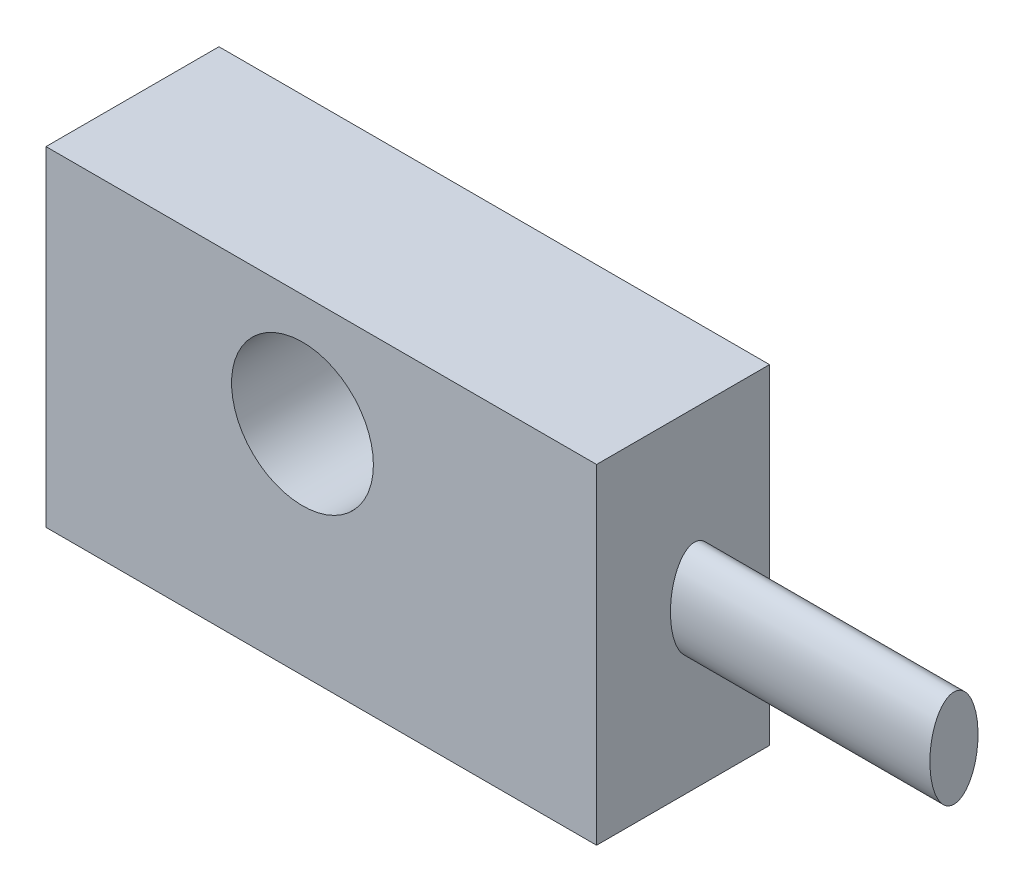
from build123d import *

# Parameters (mm, degrees)
SKETCH1_W           = 161.724310644
SKETCH1_H           = 96.872862076
BOSS_EXTRUDE1_DEPTH = 50.8
SKETCH2_R           = 20.831004362
CUT_EXTRUDE1_DEPTH  = 108.076682873
SKETCH3_RX          = 14.294101548
SKETCH3_RY          = 7.07473185
BOSS_EXTRUDE2_DEPTH = 76.2


with BuildPart() as part:
    # Sketch1 → Boss-Extrude1 (new body)
    with BuildSketch(Plane.XY):
        Rectangle(SKETCH1_W, SKETCH1_H)
    extrude(amount=BOSS_EXTRUDE1_DEPTH)

    # Sketch2 → Cut-Extrude1 (cut, through all)
    with BuildSketch(Plane.XY.offset(50.8)):
        with Locations((-5.525694513, 15.560482637)):
            Circle(SKETCH2_R)
    extrude(amount=-CUT_EXTRUDE1_DEPTH, mode=Mode.SUBTRACT)

    # Sketch3 → Boss-Extrude2 (add)
    with BuildSketch(Plane(origin=(80.862155322, 0, 0), x_dir=(0, 0, -1), z_dir=(1, 0, 0))):
        with Locations(Location((-22.034477626, 0), (0, 0, -90))):
            Ellipse(SKETCH3_RX, SKETCH3_RY)
    extrude(amount=BOSS_EXTRUDE2_DEPTH)


solid = part.part
